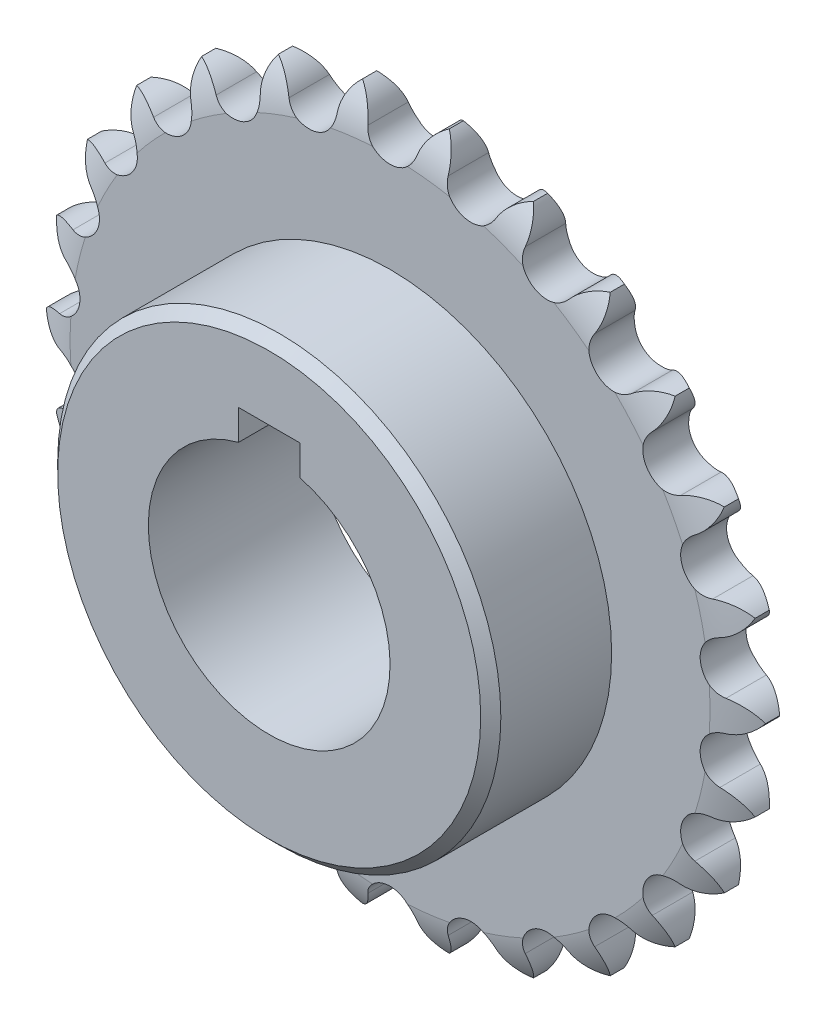
from build123d import *

# Parameters (mm, degrees)
SKETCH1_R           = 19.05
BOSS_EXTRUDE1_DEPTH = 3.6155
SKETCH2_W           = 19.05
SKETCH2_H           = 15.875
SKETCH3_W           = 9.65
SKETCH3_H           = 4.76
CUT_EXTRUDE1_DEPTH  = 85.080931
CHAMFER2_SIZE       = 1.5875


with BuildPart() as part:
    # Sketch1 → Boss-Extrude1 (new, symmetric)
    with BuildSketch(Plane.XY):
        with BuildLine():
            ThreePointArc((6.832203091, 56.268254805), (4.963717297, 54.655608899), (3.929721647, 52.414466562))
            ThreePointArc((3.929721647, 52.414466562), (0, 49.2633), (-3.929721647, 52.414466562))
            ThreePointArc((-3.929721647, 52.414466562), (-4.963717297, 54.655608899), (-6.832203091, 56.268254805))
            ThreePointArc((-6.832203091, 56.268254805), (-8.260462658, 54.25531154), (-8.728071806, 51.831841369))
            ThreePointArc((-8.728071806, 51.831841369), (-11.789479364, 47.831798034), (-16.359133961, 49.950953477))
            ThreePointArc((-16.359133961, 49.950953477), (-17.899424044, 51.879520935), (-20.099546463, 52.998148363))
            ThreePointArc((-20.099546463, 52.998148363), (-21.004574548, 50.701892683), (-20.87862145, 48.236937958))
            ThreePointArc((-20.87862145, 48.236937958), (-22.893797041, 43.620485829), (-27.837812873, 44.58447254))
            ThreePointArc((-27.837812873, 44.58447254), (-29.794881328, 46.088383789), (-32.198777254, 46.647982178))
            ThreePointArc((-32.198777254, 46.647982178), (-32.527976914, 44.201864118), (-31.815781507, 41.838679046))
            ThreePointArc((-31.815781507, 41.838679046), (-32.66761045, 36.87410954), (-37.698659287, 36.626904117))
            ThreePointArc((-37.698659287, 36.626904117), (-39.958768409, 37.618757301), (-42.426732148, 37.586804827))
            ThreePointArc((-42.426732148, 37.586804827), (-42.160971496, 35.132983877), (-40.903923988, 33.008908185))
            ThreePointArc((-40.903923988, 33.008908185), (-40.542901081, 27.984744038), (-45.368596652, 26.54071316))
            ThreePointArc((-45.368596652, 26.54071316), (-47.800397114, 26.962865377), (-50.188999585, 26.341219003))
            ThreePointArc((-50.188999585, 26.341219003), (-49.343723664, 24.022302317), (-47.614879086, 22.260779564))
            ThreePointArc((-47.614879086, 22.260779564), (-46.061985668, 17.469006932), (-50.401876088, 14.912072425))
            ThreePointArc((-50.401876088, 14.912072425), (-52.864040486, 14.739989724), (-55.034464796, 13.564777276))
            ThreePointArc((-55.034464796, 13.564777276), (-53.658797969, 11.515531863), (-51.558630485, 10.218935348))
            ThreePointArc((-51.558630485, 10.218935348), (-48.904115077, 5.93803464), (-52.505981689, 2.416796245))
            ThreePointArc((-52.505981689, 2.416796245), (-54.855417978, 1.660479445), (-56.681526955, 0))
            ThreePointArc((-56.681526955, 0), (-54.855417978, -1.660479445), (-52.505981689, -2.416796245))
            ThreePointArc((-52.505981689, -2.416796245), (-48.904115077, -5.93803464), (-51.558630485, -10.218935348))
            ThreePointArc((-51.558630485, -10.218935348), (-53.658797969, -11.515531863), (-55.034464796, -13.564777276))
            ThreePointArc((-55.034464796, -13.564777276), (-52.864040486, -14.739989724), (-50.401876088, -14.912072425))
            ThreePointArc((-50.401876088, -14.912072425), (-46.061985668, -17.469006932), (-47.614879086, -22.260779564))
            ThreePointArc((-47.614879086, -22.260779564), (-49.343723664, -24.022302317), (-50.188999585, -26.341219003))
            ThreePointArc((-50.188999585, -26.341219003), (-47.800397114, -26.962865377), (-45.368596652, -26.54071316))
            ThreePointArc((-45.368596652, -26.54071316), (-40.542901081, -27.984744038), (-40.903923988, -33.008908185))
            ThreePointArc((-40.903923988, -33.008908185), (-42.160971496, -35.132983877), (-42.426732148, -37.586804827))
            ThreePointArc((-42.426732148, -37.586804827), (-39.958768409, -37.618757301), (-37.698659287, -36.626904117))
            ThreePointArc((-37.698659287, -36.626904117), (-32.66761045, -36.87410954), (-31.815781507, -41.838679046))
            ThreePointArc((-31.815781507, -41.838679046), (-32.527976914, -44.201864118), (-32.198777254, -46.647982178))
            ThreePointArc((-32.198777254, -46.647982178), (-29.794881328, -46.088383789), (-27.837812873, -44.58447254))
            ThreePointArc((-27.837812873, -44.58447254), (-22.893797041, -43.620485829), (-20.87862145, -48.236937958))
            ThreePointArc((-20.87862145, -48.236937958), (-21.004574548, -50.701892683), (-20.099546463, -52.998148363))
            ThreePointArc((-20.099546463, -52.998148363), (-17.899424044, -51.879520935), (-16.359133961, -49.950953477))
            ThreePointArc((-16.359133961, -49.950953477), (-11.789479364, -47.831798034), (-8.728071806, -51.831841369))
            ThreePointArc((-8.728071806, -51.831841369), (-8.260462658, -54.25531154), (-6.832203091, -56.268254805))
            ThreePointArc((-6.832203091, -56.268254805), (-4.963717297, -54.655608899), (-3.929721647, -52.414466562))
            ThreePointArc((-3.929721647, -52.414466562), (0, -49.2633), (3.929721647, -52.414466562))
            ThreePointArc((3.929721647, -52.414466562), (4.963717297, -54.655608899), (6.832203091, -56.268254805))
            ThreePointArc((6.832203091, -56.268254805), (8.260462658, -54.25531154), (8.728071806, -51.831841369))
            ThreePointArc((8.728071806, -51.831841369), (11.789479365, -47.831798034), (16.359133961, -49.950953477))
            ThreePointArc((16.359133961, -49.950953477), (17.899424044, -51.879520935), (20.099546463, -52.998148363))
            ThreePointArc((20.099546463, -52.998148363), (21.004574548, -50.701892683), (20.87862145, -48.236937958))
            ThreePointArc((20.87862145, -48.236937958), (22.893797041, -43.620485829), (27.837812873, -44.58447254))
            ThreePointArc((27.837812873, -44.58447254), (29.794881328, -46.088383789), (32.198777254, -46.647982178))
            ThreePointArc((32.198777254, -46.647982178), (32.527976914, -44.201864118), (31.815781507, -41.838679046))
            ThreePointArc((31.815781507, -41.838679046), (32.66761045, -36.87410954), (37.698659287, -36.626904117))
            ThreePointArc((37.698659287, -36.626904117), (39.958768409, -37.618757301), (42.426732148, -37.586804827))
            ThreePointArc((42.426732148, -37.586804827), (42.160971496, -35.132983877), (40.903923988, -33.008908185))
            ThreePointArc((40.903923988, -33.008908185), (40.542901081, -27.984744038), (45.368596652, -26.54071316))
            ThreePointArc((45.368596652, -26.54071316), (47.800397114, -26.962865377), (50.188999585, -26.341219003))
            ThreePointArc((50.188999585, -26.341219003), (49.343723664, -24.022302317), (47.614879086, -22.260779564))
            ThreePointArc((47.614879086, -22.260779564), (46.061985668, -17.469006932), (50.401876088, -14.912072425))
            ThreePointArc((50.401876088, -14.912072425), (52.864040486, -14.739989724), (55.034464796, -13.564777276))
            ThreePointArc((55.034464796, -13.564777276), (53.658797969, -11.515531863), (51.558630485, -10.218935348))
            ThreePointArc((51.558630485, -10.218935348), (48.904115077, -5.93803464), (52.505981689, -2.416796245))
            ThreePointArc((52.505981689, -2.416796245), (54.855417978, -1.660479445), (56.681526955, 0))
            ThreePointArc((56.681526955, 0), (54.855417978, 1.660479445), (52.505981689, 2.416796245))
            ThreePointArc((52.505981689, 2.416796245), (48.904115077, 5.93803464), (51.558630485, 10.218935348))
            ThreePointArc((51.558630485, 10.218935348), (53.658797969, 11.515531863), (55.034464796, 13.564777276))
            ThreePointArc((55.034464796, 13.564777276), (52.864040486, 14.739989724), (50.401876088, 14.912072425))
            ThreePointArc((50.401876088, 14.912072425), (46.061985668, 17.469006932), (47.614879086, 22.260779564))
            ThreePointArc((47.614879086, 22.260779564), (49.343723664, 24.022302317), (50.188999585, 26.341219003))
            ThreePointArc((50.188999585, 26.341219003), (47.800397114, 26.962865377), (45.368596652, 26.54071316))
            ThreePointArc((45.368596652, 26.54071316), (40.542901081, 27.984744038), (40.903923988, 33.008908185))
            ThreePointArc((40.903923988, 33.008908185), (42.160971496, 35.132983877), (42.426732148, 37.586804827))
            ThreePointArc((42.426732148, 37.586804827), (39.958768409, 37.618757301), (37.698659287, 36.626904117))
            ThreePointArc((37.698659287, 36.626904117), (32.66761045, 36.87410954), (31.815781507, 41.838679046))
            ThreePointArc((31.815781507, 41.838679046), (32.527976914, 44.201864118), (32.198777254, 46.647982178))
            ThreePointArc((32.198777254, 46.647982178), (29.794881328, 46.088383789), (27.837812873, 44.58447254))
            ThreePointArc((27.837812873, 44.58447254), (22.893797041, 43.620485829), (20.87862145, 48.236937958))
            ThreePointArc((20.87862145, 48.236937958), (21.004574548, 50.701892683), (20.099546463, 52.998148363))
            ThreePointArc((20.099546463, 52.998148363), (17.899424044, 51.879520935), (16.359133961, 49.950953477))
            ThreePointArc((16.359133961, 49.950953477), (11.789479364, 47.831798034), (8.728071806, 51.831841369))
            ThreePointArc((8.728071806, 51.831841369), (8.260462658, 54.25531154), (6.832203091, 56.268254805))
        make_face()
        Circle(SKETCH1_R, mode=Mode.SUBTRACT)
    extrude(amount=BOSS_EXTRUDE1_DEPTH, both=True)

    # Sketch2 → Revolve1 (revolve)
    with BuildSketch(Plane(origin=(0, 0, 0), x_dir=(0, 0, -1), z_dir=(1, 0, 0))):
        with Locations((-13.1405, 26.9875)):
            Rectangle(SKETCH2_W, SKETCH2_H)
    revolve(axis=Axis((0, 0, 0), (0, 0, 1)))

    # Sketch3 → Cut-Extrude1 (cut, through all)
    with BuildSketch(Plane.XY.offset(22.6655)):
        with Locations((0, 20.808832709)):
            Rectangle(SKETCH3_W, SKETCH3_H)
    extrude(amount=-CUT_EXTRUDE1_DEPTH, mode=Mode.SUBTRACT)

    # Sketch4 → Cut-Revolve1 (revolve, cut)
    with BuildSketch(Plane(origin=(0, 0, 0), x_dir=(0, 0, -1), z_dir=(1, 0, 0))):
        with BuildLine():
            Line((-3.6155, 50.42), (-12.330867659, 50.42))
            Line((-12.330867659, 50.42), (-12.330867659, 56.89))
            Line((-12.330867659, 56.89), (-0.954045736, 56.89))
            ThreePointArc((-0.954045736, 56.89), (-2.739073023, 53.841877757), (-3.6155, 50.42))
        make_face()
    cut_revolve1 = revolve(axis=Axis((0, 0, 0), (0, 0, 1)), mode=Mode.SUBTRACT)

    # Mirror1: Cut-Revolve1 across plane
    add(cut_revolve1.mirror(Plane.XY), mode=Mode.SUBTRACT)

    # Chamfer2
    chamfer2_edges = [part.edges().sort_by_distance(p)[0] for p in [
        (0, -34.925, 22.6655),
    ]]
    chamfer(chamfer2_edges, length=CHAMFER2_SIZE)


solid = part.part
